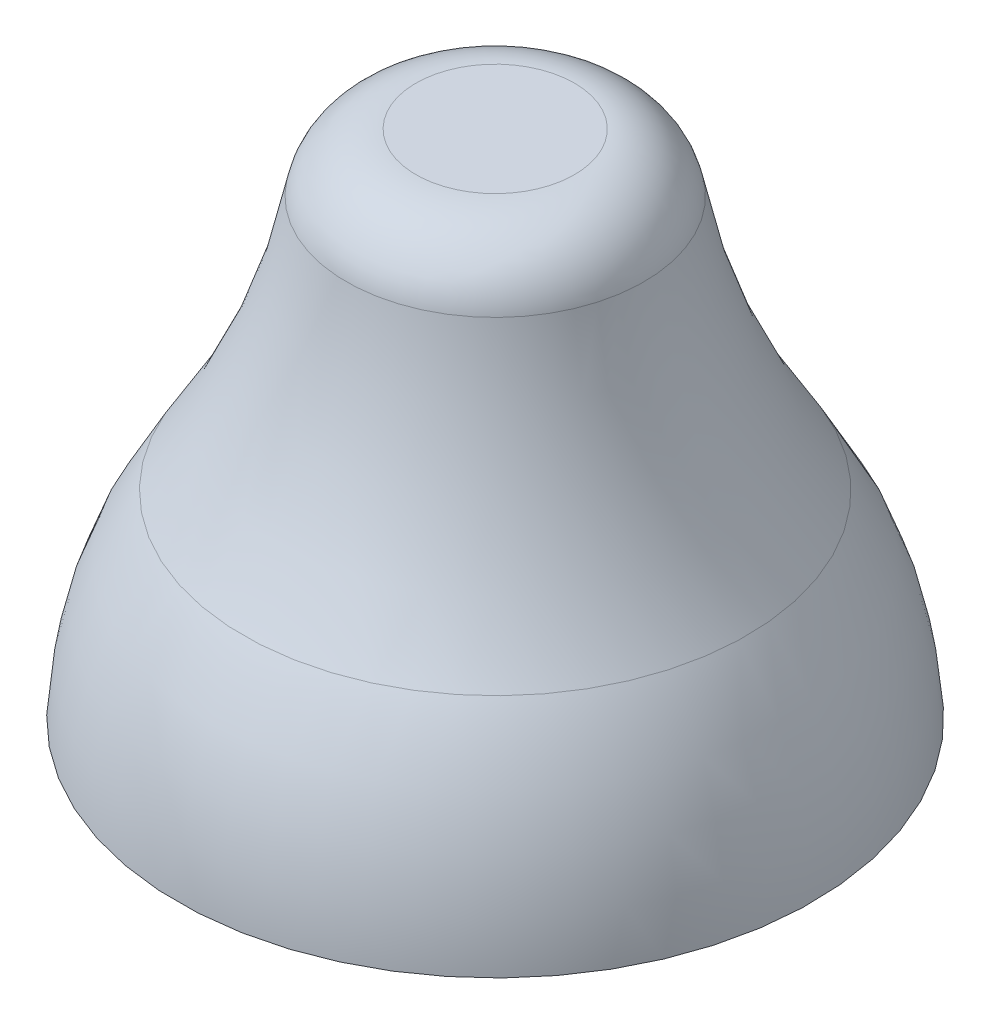
from build123d import *


with BuildPart() as part:
    # Sketch1 → Revolve1 (revolve)
    with BuildSketch(Plane.XY):
        with BuildLine():
            Line((0, 0), (0.9, 0))
            ThreePointArc((0.9, 0), (0.845516269, 0.293747377), (0.714, 0.562))
            ThreePointArc((0.714, 0.562), (0.530467505, 0.908354602), (0.421913687, 1.285))
            ThreePointArc((0.421913687, 1.285), (0.353452326, 1.403297097), (0.225, 1.45))
            Line((0.225, 1.45), (0, 1.45))
            Line((0, 1.45), (0, 0))
        make_face()
    revolve(axis=Axis((0, 0, 0), (0, 1, 0)))


solid = part.part
